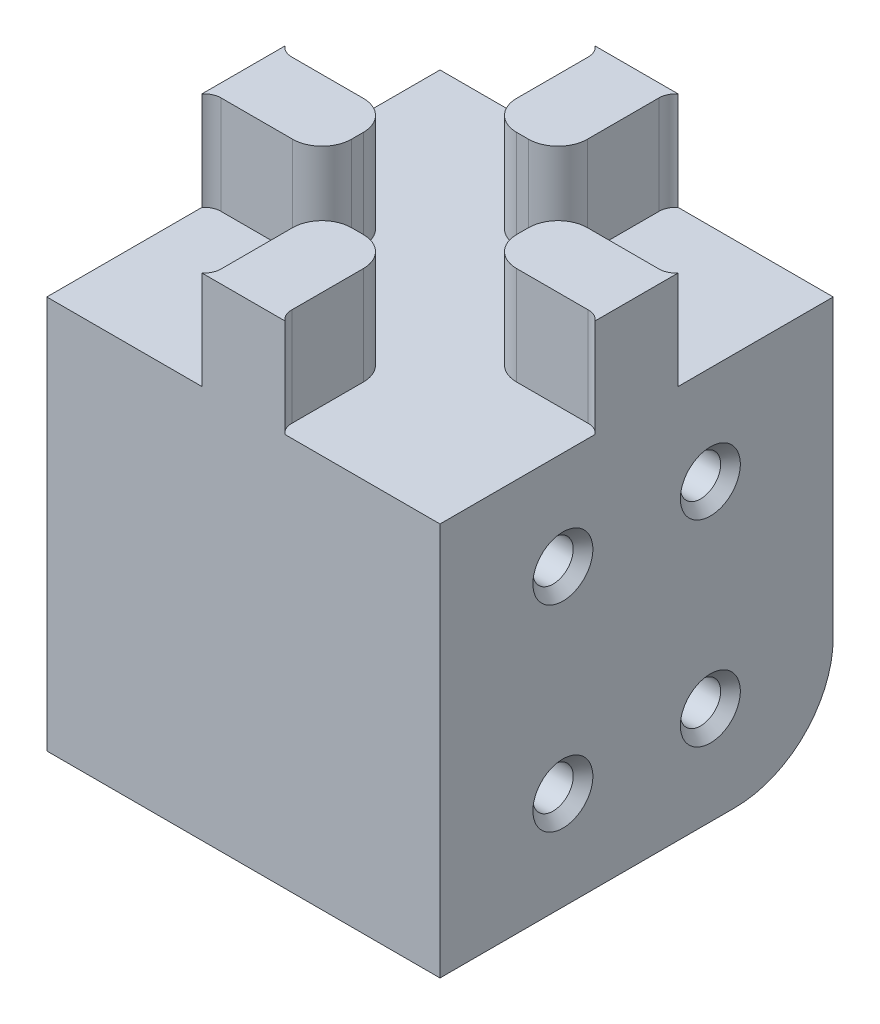
from build123d import *

# Parameters (mm, degrees)
SKETCH1_W           = 40
SKETCH1_H           = 40
BOSS_EXTRUDE1_DEPTH = 20
CUT_EXTRUDE1_START  = 13
SKETCH2_R           = 2.05
CUT_EXTRUDE1_DEPTH  = 34
BOSS_EXTRUDE2_DEPTH = 10
FILLET1_R           = 10
CHAMFER1_SIZE       = 1
FILLET2_R           = 3


with BuildPart() as part:
    # Sketch1 → Boss-Extrude1 (new body, symmetric)
    with BuildSketch(Plane(origin=(0, 0, 0), x_dir=(1, 0, 0), z_dir=(0, 1, 0))):
        Rectangle(SKETCH1_W, SKETCH1_H)
    extrude(amount=BOSS_EXTRUDE1_DEPTH, both=True)

    # Sketch2 → Cut-Extrude1 (cut, through all)
    with BuildSketch(Plane(origin=(0, 0, 0), x_dir=(0, 0, -1), z_dir=(1, 0, 0)).offset(CUT_EXTRUDE1_START)):
        with Locations((-7.5, 10)):
            Circle(SKETCH2_R)
        with Locations((7.5, 10)):
            Circle(SKETCH2_R)
        with Locations((-7.5, -10)):
            Circle(SKETCH2_R)
        with Locations((7.5, -10)):
            Circle(SKETCH2_R)
    cut_extrude1 = extrude(amount=-CUT_EXTRUDE1_DEPTH, mode=Mode.SUBTRACT)

    # Mirror1: Cut-Extrude1 across plane
    add(cut_extrude1.mirror(Plane(origin=(0, 0, 0), x_dir=(0, 0, 1), z_dir=(1, 0, 0))), mode=Mode.SUBTRACT)

    # Sketch3 → Boss-Extrude2 (add)
    with BuildSketch(Plane(origin=(0, 20, 0), x_dir=(1, 0, 0), z_dir=(0, 1, 0))):
        with BuildLine():
            Line((18.68, 3.6), (8.4, 3.6))
            Line((8.4, 3.6), (8.4, -3.6))
            Line((8.4, -3.6), (18.68, -3.6))
            ThreePointArc((18.68, -3.6), (19.408599647, -3.761942699), (20, -4.2172761))
            Line((20, -4.2172761), (20, 4.2172761))
            ThreePointArc((20, 4.2172761), (19.408599647, 3.761942699), (18.68, 3.6))
        make_face()
        with BuildLine():
            ThreePointArc((3.6, 18.68), (3.761942699, 19.408599647), (4.2172761, 20))
            Line((4.2172761, 20), (-4.2172761, 20))
            ThreePointArc((-4.2172761, 20), (-3.761942699, 19.408599647), (-3.6, 18.68))
            Line((-3.6, 18.68), (-3.6, 8.4))
            Line((-3.6, 8.4), (3.6, 8.4))
            Line((3.6, 8.4), (3.6, 18.68))
        make_face()
        with BuildLine():
            Line((-4.2172761, -20), (4.2172761, -20))
            ThreePointArc((4.2172761, -20), (3.761942699, -19.408599647), (3.6, -18.68))
            Line((3.6, -18.68), (3.6, -8.4))
            Line((3.6, -8.4), (-3.6, -8.4))
            Line((-3.6, -8.4), (-3.6, -18.68))
            ThreePointArc((-3.6, -18.68), (-3.761942699, -19.408599647), (-4.2172761, -20))
        make_face()
        with BuildLine():
            ThreePointArc((-18.68, 3.6), (-19.408599647, 3.761942699), (-20, 4.2172761))
            Line((-20, 4.2172761), (-20, -4.2172761))
            ThreePointArc((-20, -4.2172761), (-19.408599647, -3.761942699), (-18.68, -3.6))
            Line((-18.68, -3.6), (-8.4, -3.6))
            Line((-8.4, -3.6), (-8.4, 3.6))
            Line((-8.4, 3.6), (-18.68, 3.6))
        make_face()
    extrude(amount=BOSS_EXTRUDE2_DEPTH)

    # Fillet1
    fillet1_edges = [part.edges().sort_by_distance(p)[0] for p in [
        (0, -20, -20),
    ]]
    fillet(fillet1_edges, radius=FILLET1_R)

    # Chamfer1
    chamfer1_edges = [part.edges().sort_by_distance(p)[0] for p in [
        (-20, 10, -5.45),
        (-20, -10, 9.55),
        (-20, -10, -5.45),
        (-20, 10, 9.55),
        (20, 10, -5.45),
        (20, -10, 9.55),
        (20, -10, -5.45),
        (20, 10, 9.55),
    ]]
    chamfer(chamfer1_edges, length=CHAMFER1_SIZE)

    # Fillet2
    fillet2_edges = [part.edges().sort_by_distance(p)[0] for p in [
        (8.4, 25, -3.6),
        (8.4, 25, 3.6),
        (-8.4, 25, 3.6),
        (-8.4, 25, -3.6),
        (-3.6, 25, -8.4),
        (3.6, 25, -8.4),
        (3.6, 25, 8.4),
        (-3.6, 25, 8.4),
    ]]
    fillet(fillet2_edges, radius=FILLET2_R)


solid = part.part
